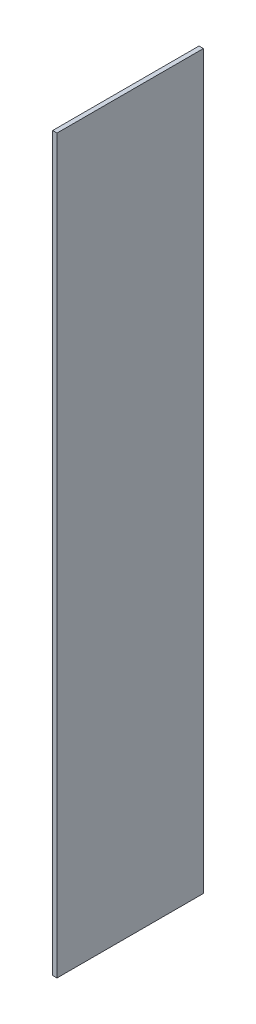
from build123d import *

# Parameters (mm, degrees)
SKETCH1_W           = 1.5
SKETCH1_H           = 50
BOSS_EXTRUDE1_DEPTH = 125


with BuildPart() as part:
    # Sketch1 → Boss-Extrude1 (new body, symmetric)
    with BuildSketch(Plane(origin=(0, 0, 0), x_dir=(1, 0, 0), z_dir=(0, 1, 0))):
        Rectangle(SKETCH1_W, SKETCH1_H)
    extrude(amount=BOSS_EXTRUDE1_DEPTH, both=True)


solid = part.part
